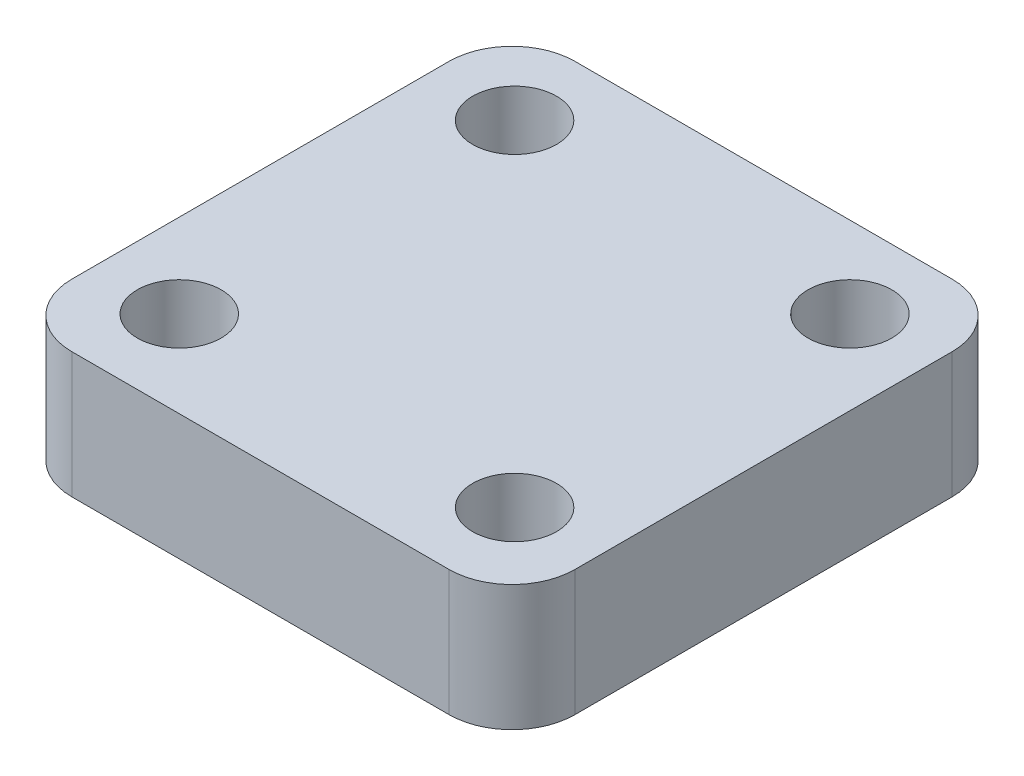
from build123d import *

# Parameters (mm, degrees)
IZIM1_R                     = 100
Y_KSEKLIK_EKSTR_ZYON1_DEPTH = 300


with BuildPart() as part:
    # Çizim1 → Yükseklik-Ekstrüzyon1 (new body)
    with BuildSketch(Plane(origin=(0, 0, 0), x_dir=(1, 0, 0), z_dir=(0, 1, 0))):
        with BuildLine():
            Line((-450, 600), (450, 600))
            ThreePointArc((450, 600), (556.066017178, 556.066017178), (600, 450))
            Line((600, 450), (600, -450))
            ThreePointArc((600, -450), (556.066017178, -556.066017178), (450, -600))
            Line((450, -600), (-450, -600))
            ThreePointArc((-450, -600), (-556.066017178, -556.066017178), (-600, -450))
            Line((-600, -450), (-600, 450))
            ThreePointArc((-600, 450), (-556.066017178, 556.066017178), (-450, 600))
        make_face()
        with Locations((-400, 406.171481212)):
            Circle(IZIM1_R, mode=Mode.SUBTRACT)
        with Locations((400, 406.171481212)):
            Circle(IZIM1_R, mode=Mode.SUBTRACT)
        with Locations((-400, -393.828518788)):
            Circle(IZIM1_R, mode=Mode.SUBTRACT)
        with Locations((400, -393.828518788)):
            Circle(IZIM1_R, mode=Mode.SUBTRACT)
    extrude(amount=Y_KSEKLIK_EKSTR_ZYON1_DEPTH)


solid = part.part
